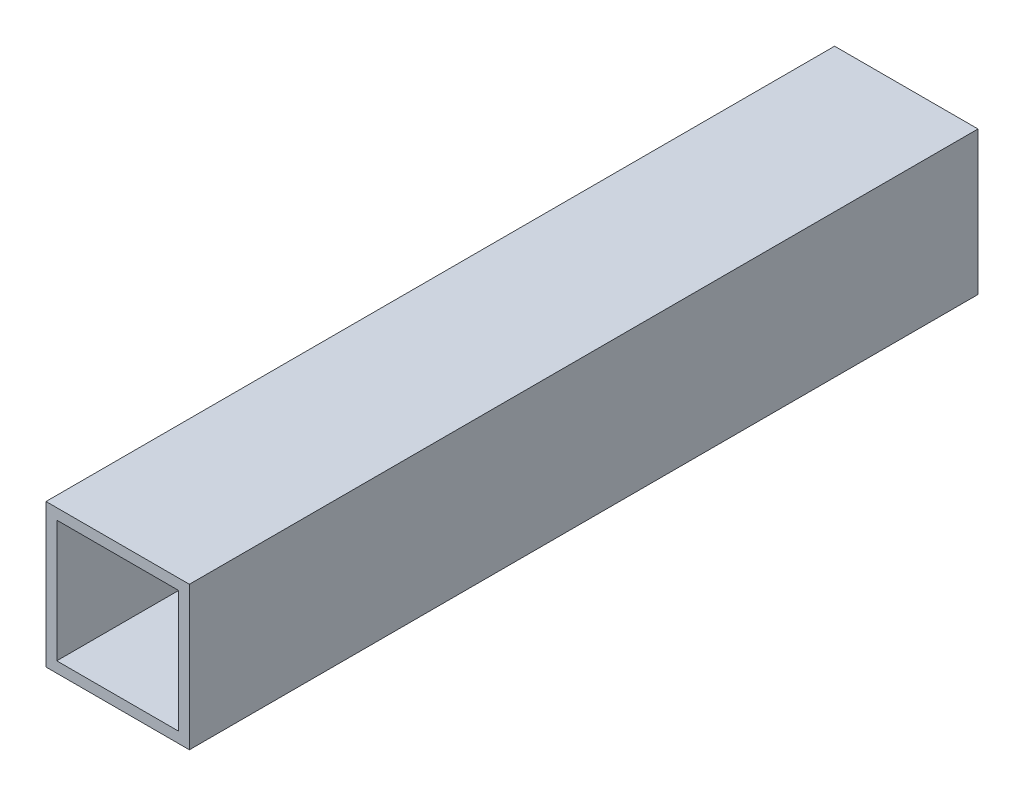
from build123d import *

# Parameters (mm, degrees)
SKETCH1_W           = 40
SKETCH1_H           = 40
SKETCH1_W_2         = 34
SKETCH1_H_2         = 34
BOSS_EXTRUDE1_DEPTH = 220


with BuildPart() as part:
    # Sketch1 → Boss-Extrude1 (new body)
    with BuildSketch(Plane.XY):
        Rectangle(SKETCH1_W, SKETCH1_H)
        Rectangle(SKETCH1_W_2, SKETCH1_H_2, mode=Mode.SUBTRACT)
    extrude(amount=BOSS_EXTRUDE1_DEPTH)


solid = part.part
